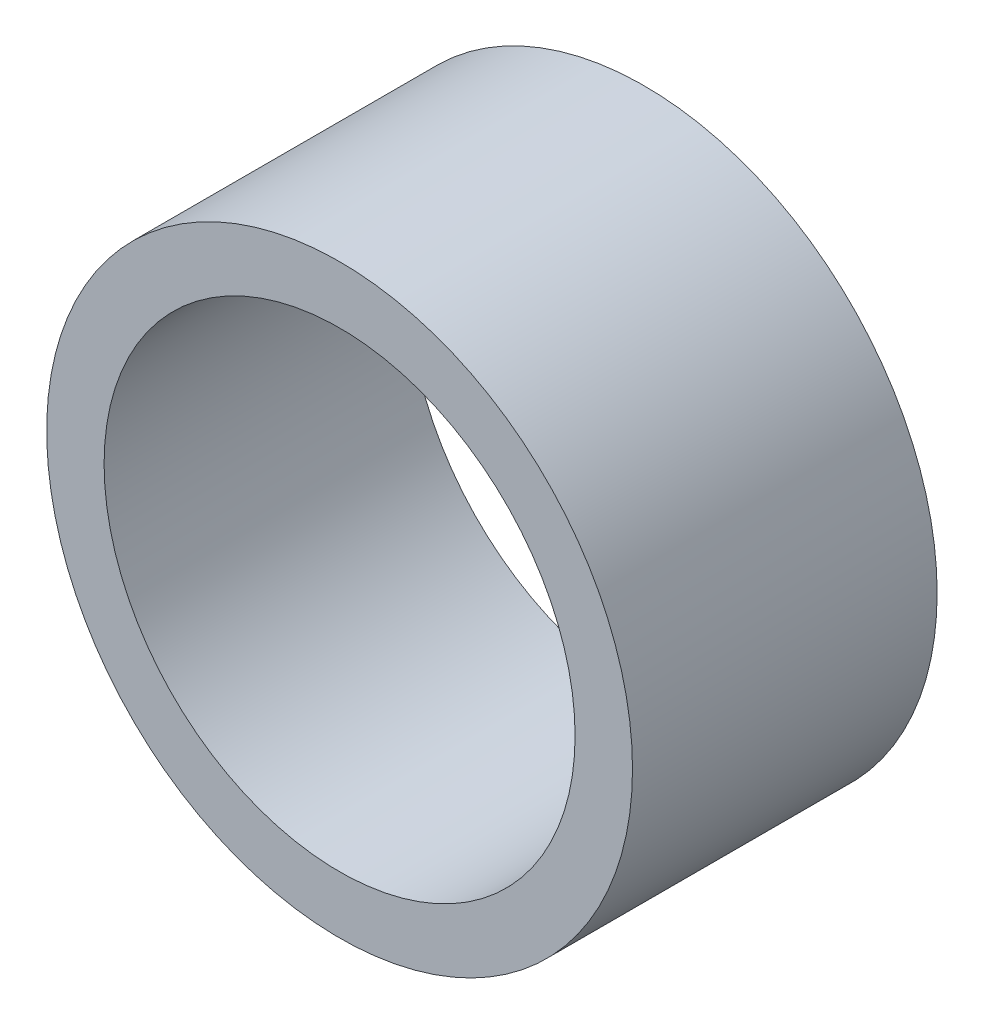
from build123d import *

# Parameters (mm, degrees)
SKETCH3_R                = 6.35
SKETCH3_R_2              = 5.1054
BOSS_EXTRUDE1_DEPTH      = 3.302
BOSS_EXTRUDE1_DEPTH_BACK = 3.302


with BuildPart() as part:
    # Sketch3 → Boss-Extrude1 (new body, two sides)
    with BuildSketch(Plane.XY) as boss_extrude1_sk:
        Circle(SKETCH3_R)
        Circle(SKETCH3_R_2, mode=Mode.SUBTRACT)
    extrude(amount=BOSS_EXTRUDE1_DEPTH)
    extrude(boss_extrude1_sk.sketch, amount=-BOSS_EXTRUDE1_DEPTH_BACK)


solid = part.part
